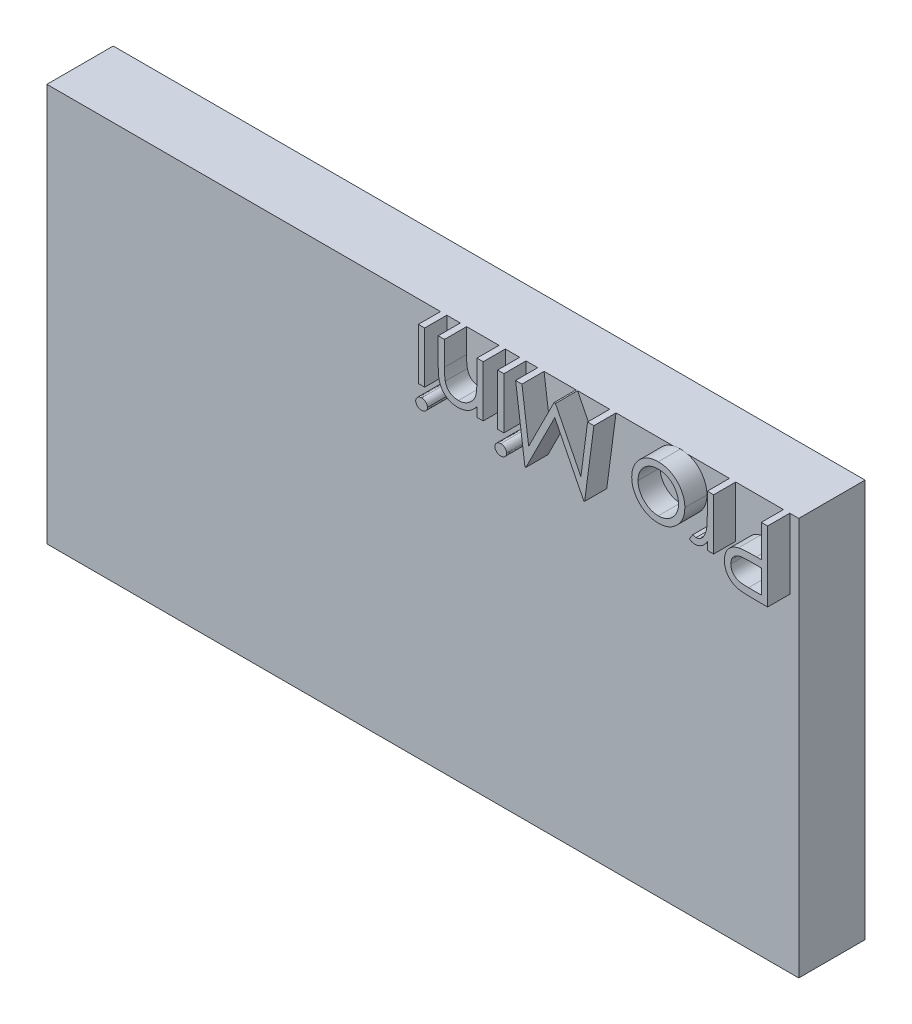
from build123d import *

# Parameters (mm, degrees)
SKETCH1_W           = 34
SKETCH1_H           = 18
BOSS_EXTRUDE1_DEPTH = 3
SKETCH2_W           = 0.284935898
SKETCH2_H           = 2.320192308
BOSS_EXTRUDE2_DEPTH = 1


with BuildPart() as part:
    # Sketch1 → Boss-Extrude1 (new body)
    with BuildSketch(Plane.XY):
        with Locations((-17, 9)):
            Rectangle(SKETCH1_W, SKETCH1_H)
    extrude(amount=BOSS_EXTRUDE1_DEPTH)

    # Sketch2 → Boss-Extrude2 (add)
    with BuildSketch(Plane.XY.offset(3)):
        with BuildLine():
            Line((-0.407051282, 14.825), (-1.02971254, 14.825))
            add(Edge.make_bspline(
                [(-1.02971254, 14.825), (-1.072539576, 14.825047077), (-1.15459808, 14.82513728), (-1.272268166, 14.827872085), (-1.379138423, 14.83152487), (-1.474978411, 14.836588444), (-1.560083014, 14.842572494), (-1.634067136, 14.850965415), (-1.697512305, 14.859728683), (-1.735527441, 14.868638102), (-1.752864583, 14.872701322)],
                knots=[0, 0, 0, 0, 0.000128477, 0.000246168, 0.000353087, 0.00044926, 0.000534089, 0.000608961, 0.000672646, 0.000726041, 0.000726041, 0.000726041, 0.000726041], degree=3))
            add(Edge.make_bspline(
                [(-1.752864583, 14.872701322), (-1.774811435, 14.878708558), (-1.818187989, 14.890581476), (-1.880693096, 14.914358446), (-1.940152308, 14.942564145), (-1.99681434, 14.974662729), (-2.049708507, 15.012170044), (-2.100486265, 15.052921295), (-2.148082732, 15.098564559), (-2.191779216, 15.149039743), (-2.232265895, 15.2026933), (-2.266156148, 15.260893367), (-2.296082575, 15.321620959), (-2.319404511, 15.38635876), (-2.33773645, 15.454252238), (-2.35108762, 15.5254781), (-2.359668703, 15.599882695), (-2.360482939, 15.650738752), (-2.360897436, 15.676627604)],
                knots=[0, 0, 0, 0, 6.8232e-05, 0.000134856, 0.000200292, 0.000265532, 0.000329934, 0.000394598, 0.000460723, 0.000527435, 0.000594727, 0.000662027, 0.00072916, 0.000797572, 0.000868081, 0.000939932, 0.001014804, 0.001092439, 0.001092439, 0.001092439, 0.001092439], degree=3))
            add(Edge.make_bspline(
                [(-2.360897436, 15.676627604), (-2.360515143, 15.702733159), (-2.359767162, 15.75381044), (-2.350789818, 15.828534326), (-2.33869743, 15.899943151), (-2.320103675, 15.967878582), (-2.295750815, 16.031937173), (-2.267183024, 16.093097862), (-2.232726536, 16.150320136), (-2.19313444, 16.203811736), (-2.149091208, 16.25362287), (-2.100783186, 16.299392577), (-2.048405399, 16.340852941), (-1.992124307, 16.37809691), (-1.93139123, 16.410260821), (-1.867127277, 16.439069233), (-1.798773866, 16.463263695), (-1.751473157, 16.475990965), (-1.727423878, 16.482461939)],
                knots=[0, 0, 0, 0, 7.8272e-05, 0.000153144, 0.000225504, 0.0002954, 0.000364034, 0.000430891, 0.000497646, 0.000564048, 0.000630282, 0.000696867, 0.000763418, 0.000830451, 0.000899029, 0.000969354, 0.001041572, 0.001116269, 0.001116269, 0.001116269, 0.001116269], degree=3))
            add(Edge.make_bspline(
                [(-1.727423878, 16.482461939), (-1.707532427, 16.486688777), (-1.663939156, 16.495952137), (-1.592149903, 16.506363894), (-1.508523467, 16.514902673), (-1.413344382, 16.522871129), (-1.306390695, 16.527093415), (-1.187907704, 16.532051068), (-1.057494423, 16.534390313), (-0.966535226, 16.534538182), (-0.919045473, 16.534615385)],
                knots=[0, 0, 0, 0, 6.0995e-05, 0.000133673, 0.000217466, 0.000313174, 0.000420146, 0.000538529, 0.000668937, 0.000811407, 0.000811407, 0.000811407, 0.000811407], degree=3))
            Line((-0.919045473, 16.534615385), (-0.691987179, 16.534615385))
            Line((-0.691987179, 16.534615385), (-0.691987179, 18))
            Line((-0.691987179, 18), (-0.407051282, 18))
            Line((-0.407051282, 18), (-0.407051282, 14.825))
        make_face()
        with BuildLine():
            Line((-0.691987179, 15.150641026), (-0.691987179, 16.208974359))
            Line((-0.691987179, 16.208974359), (-1.247866587, 16.215970553))
            add(Edge.make_bspline(
                [(-1.247866587, 16.215970553), (-1.27500869, 16.21598845), (-1.327405962, 16.216022999), (-1.403299801, 16.21234584), (-1.473542259, 16.208345506), (-1.538237046, 16.201876016), (-1.597088879, 16.193985255), (-1.650240245, 16.183435268), (-1.698115318, 16.172674962), (-1.7532621, 16.154003923), (-1.81503228, 16.125836289), (-1.8820748, 16.083764418), (-1.939357135, 16.030764439), (-1.988508131, 15.970529413), (-2.027358635, 15.903449897), (-2.05551528, 15.831877993), (-2.072701512, 15.756085468), (-2.074861675, 15.704277864), (-2.075961538, 15.677899639)],
                knots=[0, 0, 0, 0, 8.1413e-05, 0.000157166, 0.000227904, 0.000292456, 0.00035218, 0.000405942, 0.000454998, 0.000499245, 0.00058036, 0.000658165, 0.000735602, 0.000813379, 0.000890612, 0.000967146, 0.001043375, 0.001122449, 0.001122449, 0.001122449, 0.001122449], degree=3))
            add(Edge.make_bspline(
                [(-2.075961538, 15.677899639), (-2.074812606, 15.652375996), (-2.07252867, 15.601638153), (-2.055657245, 15.527242072), (-2.027060448, 15.456483828), (-1.988476458, 15.389935981), (-1.940503293, 15.329861051), (-1.884360184, 15.278042247), (-1.820920632, 15.236100993), (-1.762368562, 15.208181099), (-1.70996907, 15.191808252), (-1.664674476, 15.179987886), (-1.613272039, 15.171835631), (-1.556248221, 15.164035455), (-1.493676029, 15.157739017), (-1.425157582, 15.153366568), (-1.35092111, 15.150834445), (-1.299386048, 15.15070706), (-1.272671274, 15.150641026)],
                knots=[0, 0, 0, 0, 7.6536e-05, 0.000152145, 0.000227496, 0.00030473, 0.000382107, 0.000457279, 0.000532954, 0.000609493, 0.000650927, 0.000697513, 0.000749794, 0.000806912, 0.000870198, 0.000938398, 0.001012855, 0.001092996, 0.001092996, 0.001092996, 0.001092996], degree=3))
            Line((-1.272671274, 15.150641026), (-0.691987179, 15.150641026))
        make_face(mode=Mode.SUBTRACT)
        with BuildLine():
            Line((-2.849358974, 15.679807692), (-3.134294872, 15.679807692))
            Line((-3.134294872, 15.679807692), (-3.134294872, 16.021349159))
            add(Edge.make_bspline(
                [(-3.134294872, 16.021349159), (-3.155314407, 15.989530955), (-3.195514105, 15.928678888), (-3.262684354, 15.848357715), (-3.330732214, 15.780796103), (-3.40197261, 15.728246628), (-3.474593876, 15.688202126), (-3.548381179, 15.659822236), (-3.62386702, 15.642523734), (-3.674821896, 15.640244482), (-3.700350561, 15.639102564)],
                knots=[0, 0, 0, 0, 0.000114321, 0.000218637, 0.00031354, 0.000401313, 0.00048329, 0.000561603, 0.000637832, 0.000714369, 0.000714369, 0.000714369, 0.000714369], degree=3))
            add(Edge.make_bspline(
                [(-3.700350561, 15.639102564), (-3.720156572, 15.640158381), (-3.760702442, 15.642319797), (-3.822266703, 15.658265916), (-3.885958304, 15.682758748), (-3.927059765, 15.706354909), (-3.948397436, 15.718604768)],
                knots=[0, 0, 0, 0, 5.9368e-05, 0.000121535, 0.000189803, 0.000263507, 0.000263507, 0.000263507, 0.000263507], degree=3))
            Line((-3.948397436, 15.718604768), (-3.791937099, 15.965379607))
            add(Edge.make_bspline(
                [(-3.791937099, 15.965379607), (-3.778231059, 15.959265223), (-3.75221437, 15.947658951), (-3.714155585, 15.933922985), (-3.679066086, 15.925834976), (-3.656710858, 15.924609682), (-3.646289062, 15.924038462)],
                knots=[0, 0, 0, 0, 4.5014e-05, 8.5445e-05, 0.000121249, 0.000152517, 0.000152517, 0.000152517, 0.000152517], degree=3))
            add(Edge.make_bspline(
                [(-3.646289062, 15.924038462), (-3.623187227, 15.925494394), (-3.57648706, 15.92843755), (-3.508251528, 15.953583794), (-3.441152363, 15.991377), (-3.389041455, 16.035957185), (-3.348242182, 16.077963873), (-3.31888172, 16.114929536), (-3.292512739, 16.156734836), (-3.266939471, 16.201796275), (-3.243178482, 16.251235354), (-3.221944969, 16.305135437), (-3.202087419, 16.363050651), (-3.190904583, 16.403320482), (-3.185176282, 16.423948317)],
                knots=[0, 0, 0, 0, 6.9113e-05, 0.000139711, 0.000215759, 0.00029931, 0.000344293, 0.000391375, 0.000440596, 0.000492426, 0.00054676, 0.000604986, 0.00066613, 0.000730342, 0.000730342, 0.000730342, 0.000730342], degree=3))
            add(Edge.make_bspline(
                [(-3.185176282, 16.423948317), (-3.180875906, 16.442341592), (-3.171303134, 16.483285597), (-3.16224405, 16.551663666), (-3.152932787, 16.632398135), (-3.146574133, 16.725582792), (-3.140567536, 16.831575842), (-3.137249244, 16.949920029), (-3.134400448, 17.080940626), (-3.134331187, 17.172326977), (-3.134294872, 17.220242388)],
                knots=[0, 0, 0, 0, 5.6638e-05, 0.000126077, 0.000206709, 0.000300465, 0.000406199, 0.000525195, 0.000655604, 0.000799345, 0.000799345, 0.000799345, 0.000799345], degree=3))
            Line((-3.134294872, 17.220242388), (-3.134294872, 18))
            Line((-3.134294872, 18), (-2.849358974, 18))
            Line((-2.849358974, 18), (-2.849358974, 15.679807692))
        make_face()
        with BuildLine():
            add(Edge.make_bspline(
                [(-5.353996394, 15.639102564), (-5.397532415, 15.640026845), (-5.482895913, 15.641839134), (-5.607892049, 15.66130409), (-5.72708493, 15.690821452), (-5.840985858, 15.73237098), (-5.948652643, 15.786885584), (-6.051046571, 15.852809962), (-6.147962492, 15.930590128), (-6.206038104, 15.990791444), (-6.235516827, 16.021349159)],
                knots=[0, 0, 0, 0, 0.000130509, 0.000255897, 0.000378531, 0.000498457, 0.000618774, 0.000739799, 0.000863267, 0.000990542, 0.000990542, 0.000990542, 0.000990542], degree=3))
            add(Edge.make_bspline(
                [(-6.235516827, 16.021349159), (-6.260900457, 16.050571846), (-6.311176473, 16.10845168), (-6.375643232, 16.202300701), (-6.431179933, 16.299492078), (-6.475687048, 16.401316438), (-6.510779891, 16.50688489), (-6.535695201, 16.616560286), (-6.550515135, 16.730100415), (-6.55251354, 16.80721104), (-6.553525641, 16.846264022)],
                knots=[0, 0, 0, 0, 0.000116043, 0.000229841, 0.000340916, 0.00045141, 0.000562633, 0.000674184, 0.000788337, 0.000905475, 0.000905475, 0.000905475, 0.000905475], degree=3))
            add(Edge.make_bspline(
                [(-6.553525641, 16.846264022), (-6.552635428, 16.885543361), (-6.550876325, 16.963161164), (-6.534236044, 17.077478731), (-6.508354275, 17.188326895), (-6.471313959, 17.295241555), (-6.423817695, 17.398549594), (-6.365859635, 17.497799511), (-6.297033544, 17.593188189), (-6.219014454, 17.683901539), (-6.132793219, 17.767519171), (-6.039236222, 17.84035323), (-5.940114193, 17.9030155), (-5.834074017, 17.952786766), (-5.722625143, 17.992905872), (-5.605058687, 18.020570578), (-5.481479527, 18.037446799), (-5.397088521, 18.039603741), (-5.353996394, 18.040705128)],
                knots=[0, 0, 0, 0, 0.000117773, 0.000232725, 0.000345804, 0.000458844, 0.000571541, 0.000686407, 0.000803078, 0.000923941, 0.00104494, 0.001162753, 0.001279048, 0.001395973, 0.001513456, 0.001633783, 0.001757643, 0.001886881, 0.001886881, 0.001886881, 0.001886881], degree=3))
            add(Edge.make_bspline(
                [(-5.353996394, 18.040705128), (-5.310695214, 18.039594628), (-5.225887666, 18.037419657), (-5.101843179, 18.020696113), (-4.983781731, 17.992610286), (-4.871805679, 17.953283431), (-4.765765933, 17.902606694), (-4.666277894, 17.840597043), (-4.572676768, 17.767482289), (-4.486428501, 17.683911533), (-4.408416659, 17.593185614), (-4.339588697, 17.497800179), (-4.281631123, 17.39854942), (-4.234134732, 17.295241601), (-4.19709445, 17.188326883), (-4.171212672, 17.077478734), (-4.154572393, 16.963161164), (-4.15281329, 16.88554336), (-4.151923077, 16.846264022)],
                knots=[0, 0, 0, 0, 0.000129874, 0.000254364, 0.000374691, 0.000493373, 0.000609724, 0.000726559, 0.000844372, 0.000965371, 0.001086234, 0.001202905, 0.001317771, 0.001430468, 0.001543508, 0.001656586, 0.001771539, 0.001889312, 0.001889312, 0.001889312, 0.001889312], degree=3))
            add(Edge.make_bspline(
                [(-4.151923077, 16.846264022), (-4.152939659, 16.807422432), (-4.154952317, 16.730522758), (-4.169792475, 16.617208642), (-4.194436687, 16.507868916), (-4.230016018, 16.402876953), (-4.274440513, 16.301297325), (-4.329418261, 16.203749592), (-4.394508629, 16.110310652), (-4.444589324, 16.052507573), (-4.469931891, 16.023257212)],
                knots=[0, 0, 0, 0, 0.000116502, 0.000230655, 0.000342206, 0.000452223, 0.000562716, 0.000674346, 0.000787621, 0.000903664, 0.000903664, 0.000903664, 0.000903664], degree=3))
            add(Edge.make_bspline(
                [(-4.469931891, 16.023257212), (-4.499368611, 15.992439641), (-4.557261101, 15.931831465), (-4.6546244, 15.854204762), (-4.756577865, 15.787391565), (-4.864939137, 15.732904397), (-4.979156775, 15.690896841), (-5.099235522, 15.661166323), (-5.224686619, 15.641925232), (-5.310463573, 15.64005283), (-5.353996394, 15.639102564)],
                knots=[0, 0, 0, 0, 0.000127724, 0.000251192, 0.000372563, 0.000492879, 0.000614219, 0.000736853, 0.000863499, 0.000994008, 0.000994008, 0.000994008, 0.000994008], degree=3))
        make_face()
        with BuildLine():
            add(Edge.make_bspline(
                [(-5.352724359, 15.924038462), (-5.321938132, 15.924913531), (-5.261160419, 15.926641081), (-5.171697869, 15.939779369), (-5.085575428, 15.960598557), (-5.002618731, 15.990165792), (-4.92314855, 16.028390619), (-4.847077735, 16.075075672), (-4.774609552, 16.130469096), (-4.70630501, 16.19347184), (-4.642869792, 16.261897925), (-4.588102071, 16.335498379), (-4.541182979, 16.41222806), (-4.502846246, 16.49252065), (-4.473434529, 16.576596743), (-4.4525954, 16.663975295), (-4.439432178, 16.75491637), (-4.437726001, 16.816750073), (-4.436858974, 16.848172075)],
                knots=[0, 0, 0, 0, 9.233e-05, 0.000182276, 0.000270667, 0.000357773, 0.00044596, 0.000534752, 0.000625069, 0.00071915, 0.000813231, 0.000904564, 0.000993899, 0.001082659, 0.001170965, 0.001260591, 0.001351797, 0.001446033, 0.001446033, 0.001446033, 0.001446033], degree=3))
            add(Edge.make_bspline(
                [(-4.436858974, 16.848172075), (-4.438312747, 16.888770351), (-4.441198213, 16.969350337), (-4.464781737, 17.087988332), (-4.50395507, 17.20209826), (-4.557972472, 17.310306208), (-4.624496528, 17.410597681), (-4.702282768, 17.500780246), (-4.792406614, 17.577376102), (-4.891799176, 17.641794507), (-4.999051934, 17.692523941), (-5.112366752, 17.72890369), (-5.230711862, 17.752234334), (-5.311697581, 17.754580619), (-5.352724359, 17.755769231)],
                knots=[0, 0, 0, 0, 0.000121719, 0.000241589, 0.000361264, 0.000482718, 0.000603375, 0.000721483, 0.000838759, 0.000956957, 0.001075879, 0.001193542, 0.001313293, 0.001436243, 0.001436243, 0.001436243, 0.001436243], degree=3))
            add(Edge.make_bspline(
                [(-5.352724359, 17.755769231), (-5.393753496, 17.754587505), (-5.474743874, 17.75225481), (-5.593253646, 17.728785489), (-5.706879023, 17.692682133), (-5.814243297, 17.641737211), (-5.913681123, 17.577619587), (-6.003161422, 17.500343887), (-6.081617547, 17.410834754), (-6.148207474, 17.310439188), (-6.201354506, 17.201930038), (-6.24071206, 17.088009358), (-6.264239025, 16.969344982), (-6.267132125, 16.888768557), (-6.268589744, 16.848172075)],
                knots=[0, 0, 0, 0, 0.000122951, 0.000242701, 0.00036097, 0.000479891, 0.00059809, 0.000714883, 0.00083341, 0.000954067, 0.00107524, 0.001194914, 0.001314785, 0.001436504, 0.001436504, 0.001436504, 0.001436504], degree=3))
            add(Edge.make_bspline(
                [(-6.268589744, 16.848172075), (-6.267729212, 16.816747547), (-6.266035817, 16.754908874), (-6.252779627, 16.664003951), (-6.232267597, 16.576422722), (-6.201587805, 16.492859737), (-6.164586715, 16.411837189), (-6.116530126, 16.335728173), (-6.062017365, 16.261851237), (-5.998465861, 16.19351306), (-5.930168986, 16.130238908), (-5.85715639, 16.075277458), (-5.781050244, 16.02836396), (-5.701554949, 15.990161085), (-5.618785979, 15.960712362), (-5.53292501, 15.939688678), (-5.443858643, 15.926688984), (-5.383296747, 15.92492762), (-5.352724359, 15.924038462)],
                knots=[0, 0, 0, 0, 9.4236e-05, 0.000185442, 0.000275068, 0.000363587, 0.000452076, 0.000541743, 0.000633075, 0.000727156, 0.000821237, 0.000912061, 0.001000853, 0.00108904, 0.001176146, 0.001263919, 0.001353866, 0.00144556, 0.00144556, 0.00144556, 0.00144556], degree=3))
        make_face(mode=Mode.SUBTRACT)
        Polygon((-8.263141026, 18), (-8.682276643, 14.825), (-8.722981771, 14.825), (-10.033814103, 17.430128205), (-11.341466346, 14.825), (-11.382807492, 14.825), (-11.804487179, 18), (-11.518279247, 18), (-11.214262821, 15.715424679), (-10.068159054, 18), (-10.003921274, 18), (-8.853365385, 15.710336538), (-8.549984976, 18), align=None)
        with BuildLine():
            add(Edge.make_bspline(
                [(-12.47484976, 14.702884615), (-12.492528215, 14.703708369), (-12.527146027, 14.705321435), (-12.577256139, 14.719024526), (-12.622838976, 14.742606406), (-12.663873212, 14.773216262), (-12.697888707, 14.810694976), (-12.722279628, 14.853279081), (-12.737850718, 14.899638508), (-12.739742122, 14.931940769), (-12.740705128, 14.94838742)],
                knots=[0, 0, 0, 0, 5.2977e-05, 0.000103739, 0.000154369, 0.000206141, 0.000256583, 0.000305021, 0.000352489, 0.000401726, 0.000401726, 0.000401726, 0.000401726], degree=3))
            add(Edge.make_bspline(
                [(-12.740705128, 14.94838742), (-12.739720579, 14.964407167), (-12.737774242, 14.996076312), (-12.722291139, 15.041631925), (-12.697684218, 15.083623055), (-12.663895852, 15.121028496), (-12.622832996, 15.151620668), (-12.577257721, 15.17520722), (-12.527145611, 15.188909077), (-12.492528075, 15.190522314), (-12.47484976, 15.191346154)],
                knots=[0, 0, 0, 0, 4.7972e-05, 9.4835e-05, 0.000142722, 0.000193165, 0.000244937, 0.000295567, 0.000346329, 0.000399306, 0.000399306, 0.000399306, 0.000399306], degree=3))
            add(Edge.make_bspline(
                [(-12.47484976, 15.191346154), (-12.457374484, 15.190548773), (-12.423361143, 15.188996774), (-12.374172409, 15.175043289), (-12.329323016, 15.151671959), (-12.288959844, 15.120605142), (-12.254501575, 15.083871777), (-12.229985447, 15.041600207), (-12.214460947, 14.996084388), (-12.212520189, 14.96440988), (-12.211538462, 14.94838742)],
                knots=[0, 0, 0, 0, 5.2343e-05, 0.000101879, 0.000151943, 0.000203209, 0.000254078, 0.000301966, 0.000348828, 0.0003968, 0.0003968, 0.0003968, 0.0003968], degree=3))
            add(Edge.make_bspline(
                [(-12.211538462, 14.94838742), (-12.212498541, 14.931937953), (-12.214384196, 14.899630162), (-12.229997496, 14.853311342), (-12.254294563, 14.810444133), (-12.288982108, 14.773639309), (-12.329317188, 14.742555228), (-12.374173927, 14.719188412), (-12.423360741, 14.705233747), (-12.457374347, 14.703681913), (-12.47484976, 14.702884615)],
                knots=[0, 0, 0, 0, 4.9237e-05, 9.6705e-05, 0.000145142, 0.000196012, 0.000247277, 0.000297341, 0.000346877, 0.00039922, 0.00039922, 0.00039922, 0.00039922], degree=3))
        make_face()
        with Locations((-12.476121795, 16.839903846)):
            Rectangle(SKETCH2_W, SKETCH2_H)
        with BuildLine():
            Line((-13.269871795, 15.679807692), (-13.554807692, 15.679807692))
            Line((-13.554807692, 15.679807692), (-13.554807692, 16.098307292))
            add(Edge.make_bspline(
                [(-13.554807692, 16.098307292), (-13.585178601, 16.060293209), (-13.64402184, 15.986641419), (-13.74302436, 15.890600216), (-13.846254533, 15.810006283), (-13.95538898, 15.746550149), (-14.069304684, 15.698558117), (-14.187678411, 15.663950206), (-14.31115086, 15.643186627), (-14.395120442, 15.640474575), (-14.43760016, 15.639102564)],
                knots=[0, 0, 0, 0, 0.000145848, 0.000282578, 0.00041272, 0.000537841, 0.000660105, 0.000782678, 0.000907106, 0.001034501, 0.001034501, 0.001034501, 0.001034501], degree=3))
            add(Edge.make_bspline(
                [(-14.43760016, 15.639102564), (-14.480556302, 15.640596271), (-14.564673977, 15.64352128), (-14.686708028, 15.66929444), (-14.801482025, 15.71008063), (-14.907461251, 15.76740361), (-15.003014998, 15.838573785), (-15.085876384, 15.922056931), (-15.155558598, 16.016847292), (-15.202068242, 16.105573295), (-15.232150185, 16.184384709), (-15.251918856, 16.251794188), (-15.267912133, 16.326926991), (-15.282242731, 16.409597358), (-15.291802813, 16.500137331), (-15.299380954, 16.598330817), (-15.304801389, 16.704160812), (-15.305017014, 16.777354999), (-15.305128205, 16.815099159)],
                knots=[0, 0, 0, 0, 0.000128741, 0.000252104, 0.000372411, 0.000493068, 0.000612131, 0.000728612, 0.000844628, 0.000963828, 0.001027848, 0.00109748, 0.00117433, 0.001258188, 0.001349074, 0.001447318, 0.001553654, 0.001666873, 0.001666873, 0.001666873, 0.001666873], degree=3))
            Line((-15.305128205, 16.815099159), (-15.305128205, 18))
            Line((-15.305128205, 18), (-15.020192308, 18))
            Line((-15.020192308, 18), (-15.020192308, 16.90859375))
            add(Edge.make_bspline(
                [(-15.020192308, 16.90859375), (-15.020017766, 16.877004772), (-15.019683897, 16.816580434), (-15.018617076, 16.730067695), (-15.01610583, 16.65182168), (-15.012431985, 16.581617519), (-15.00728953, 16.519712161), (-15.001784438, 16.465792256), (-14.995107572, 16.420335413), (-14.98915362, 16.392971409), (-14.986483373, 16.380699119)],
                knots=[0, 0, 0, 0, 9.4769e-05, 0.000181277, 0.000259548, 0.000329614, 0.000392151, 0.000445882, 0.000492207, 0.000529877, 0.000529877, 0.000529877, 0.000529877], degree=3))
            add(Edge.make_bspline(
                [(-14.986483373, 16.380699119), (-14.976892344, 16.344649521), (-14.958481674, 16.275449729), (-14.912063159, 16.18174609), (-14.854806417, 16.101322153), (-14.783866627, 16.035831942), (-14.701149056, 15.984849498), (-14.606516193, 15.949502325), (-14.500947442, 15.927387313), (-14.426693343, 15.925185885), (-14.387990785, 15.924038462)],
                knots=[0, 0, 0, 0, 0.000111666, 0.000214351, 0.000311801, 0.000406313, 0.00050198, 0.000601435, 0.00070796, 0.000823926, 0.000823926, 0.000823926, 0.000823926], degree=3))
            add(Edge.make_bspline(
                [(-14.387990785, 15.924038462), (-14.365067268, 15.924463892), (-14.319702221, 15.925305807), (-14.252468489, 15.933972426), (-14.18704617, 15.947660258), (-14.123610535, 15.967878124), (-14.062033383, 15.992460224), (-14.002059896, 16.022623616), (-13.944528075, 16.059108797), (-13.888628942, 16.100118188), (-13.836673062, 16.145787293), (-13.787639987, 16.193279986), (-13.744558364, 16.244584902), (-13.705452289, 16.297888072), (-13.671735973, 16.354260245), (-13.642293793, 16.413098833), (-13.617315678, 16.474496908), (-13.604903428, 16.517109905), (-13.598692909, 16.53843149)],
                knots=[0, 0, 0, 0, 6.8737e-05, 0.000136029, 0.000203016, 0.000268997, 0.00033549, 0.000401764, 0.000470059, 0.000539641, 0.000609525, 0.000677436, 0.000744215, 0.000810241, 0.000875578, 0.000940998, 0.001007491, 0.001074079, 0.001074079, 0.001074079, 0.001074079], degree=3))
            add(Edge.make_bspline(
                [(-13.598692909, 16.53843149), (-13.595119085, 16.554084425), (-13.587339057, 16.588160044), (-13.578936029, 16.644080338), (-13.571309157, 16.708768673), (-13.56492563, 16.78214956), (-13.561020003, 16.864479918), (-13.556761514, 16.955408143), (-13.555211152, 17.055296807), (-13.554945945, 17.124839914), (-13.554807692, 17.161092748)],
                knots=[0, 0, 0, 0, 4.8153e-05, 0.000104826, 0.000169516, 0.000243568, 0.000325735, 0.000416765, 0.000516638, 0.000625399, 0.000625399, 0.000625399, 0.000625399], degree=3))
            Line((-13.554807692, 17.161092748), (-13.554807692, 18))
            Line((-13.554807692, 18), (-13.269871795, 18))
            Line((-13.269871795, 18), (-13.269871795, 15.679807692))
        make_face()
        with BuildLine():
            add(Edge.make_bspline(
                [(-16.056901042, 14.702884615), (-16.074579497, 14.703708369), (-16.109197309, 14.705321435), (-16.159307421, 14.719024526), (-16.204890258, 14.742606406), (-16.245924494, 14.773216262), (-16.27993999, 14.810694976), (-16.30433091, 14.853279081), (-16.319902, 14.899638508), (-16.321793404, 14.931940769), (-16.32275641, 14.94838742)],
                knots=[0, 0, 0, 0, 5.2977e-05, 0.000103739, 0.000154369, 0.000206141, 0.000256583, 0.000305021, 0.000352489, 0.000401726, 0.000401726, 0.000401726, 0.000401726], degree=3))
            add(Edge.make_bspline(
                [(-16.32275641, 14.94838742), (-16.321771861, 14.964407167), (-16.319825524, 14.996076312), (-16.304342421, 15.041631925), (-16.2797355, 15.083623055), (-16.245947134, 15.121028496), (-16.204884278, 15.151620668), (-16.159309003, 15.17520722), (-16.109196893, 15.188909077), (-16.074579357, 15.190522314), (-16.056901042, 15.191346154)],
                knots=[0, 0, 0, 0, 4.7972e-05, 9.4835e-05, 0.000142722, 0.000193165, 0.000244937, 0.000295567, 0.000346329, 0.000399306, 0.000399306, 0.000399306, 0.000399306], degree=3))
            add(Edge.make_bspline(
                [(-16.056901042, 15.191346154), (-16.039425766, 15.190548773), (-16.005412426, 15.188996774), (-15.956223691, 15.175043289), (-15.911374298, 15.151671959), (-15.871011126, 15.120605142), (-15.836552857, 15.083871777), (-15.812036729, 15.041600207), (-15.796512229, 14.996084388), (-15.794571471, 14.96440988), (-15.793589744, 14.94838742)],
                knots=[0, 0, 0, 0, 5.2343e-05, 0.000101879, 0.000151943, 0.000203209, 0.000254078, 0.000301966, 0.000348828, 0.0003968, 0.0003968, 0.0003968, 0.0003968], degree=3))
            add(Edge.make_bspline(
                [(-15.793589744, 14.94838742), (-15.794549823, 14.931937953), (-15.796435478, 14.899630162), (-15.812048778, 14.853311342), (-15.836345845, 14.810444133), (-15.87103339, 14.773639309), (-15.91136847, 14.742555228), (-15.956225209, 14.719188412), (-16.005412023, 14.705233747), (-16.039425629, 14.703681913), (-16.056901042, 14.702884615)],
                knots=[0, 0, 0, 0, 4.9237e-05, 9.6705e-05, 0.000145142, 0.000196012, 0.000247277, 0.000297341, 0.000346877, 0.00039922, 0.00039922, 0.00039922, 0.00039922], degree=3))
        make_face()
        with Locations((-16.058173077, 16.839903846)):
            Rectangle(SKETCH2_W, SKETCH2_H)
    extrude(amount=BOSS_EXTRUDE2_DEPTH)


solid = part.part
